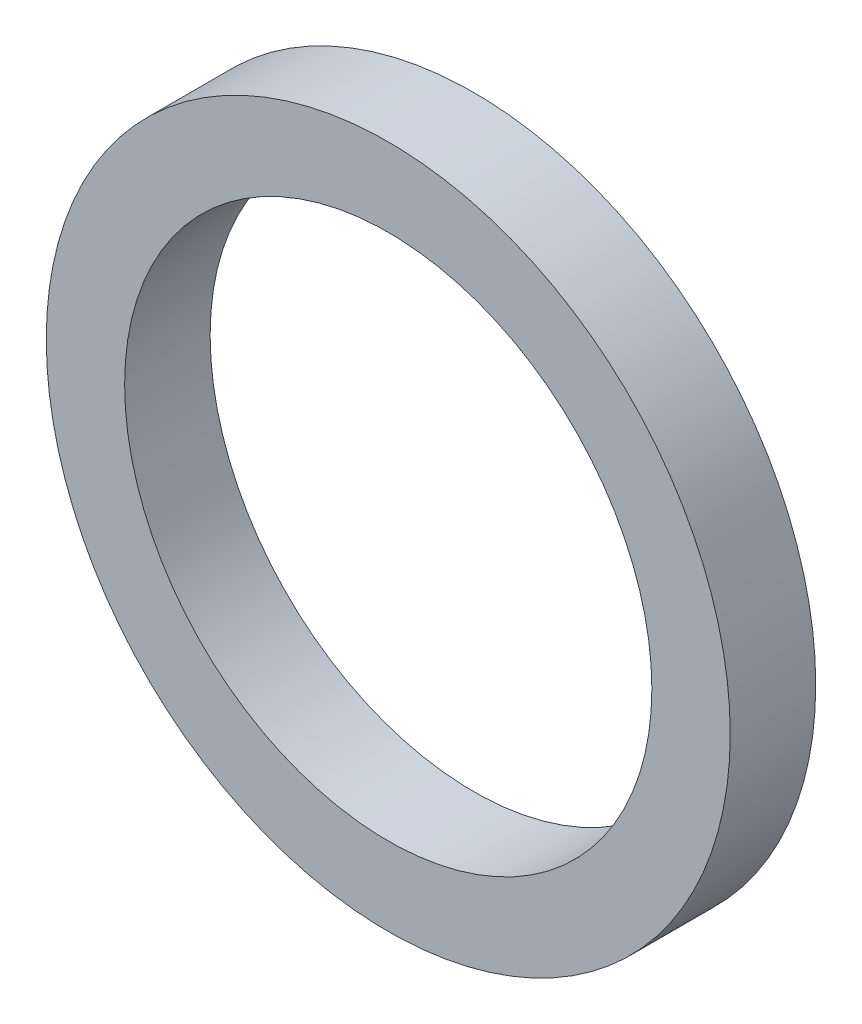
from build123d import *

# Parameters (mm, degrees)
SKETCH1_R           = 12
SKETCH1_R_2         = 9.25
BOSS_EXTRUDE1_DEPTH = 3


with BuildPart() as part:
    # Sketch1 → Boss-Extrude1 (new body)
    with BuildSketch(Plane.XY):
        Circle(SKETCH1_R)
        Circle(SKETCH1_R_2, mode=Mode.SUBTRACT)
    extrude(amount=BOSS_EXTRUDE1_DEPTH)


solid = part.part
